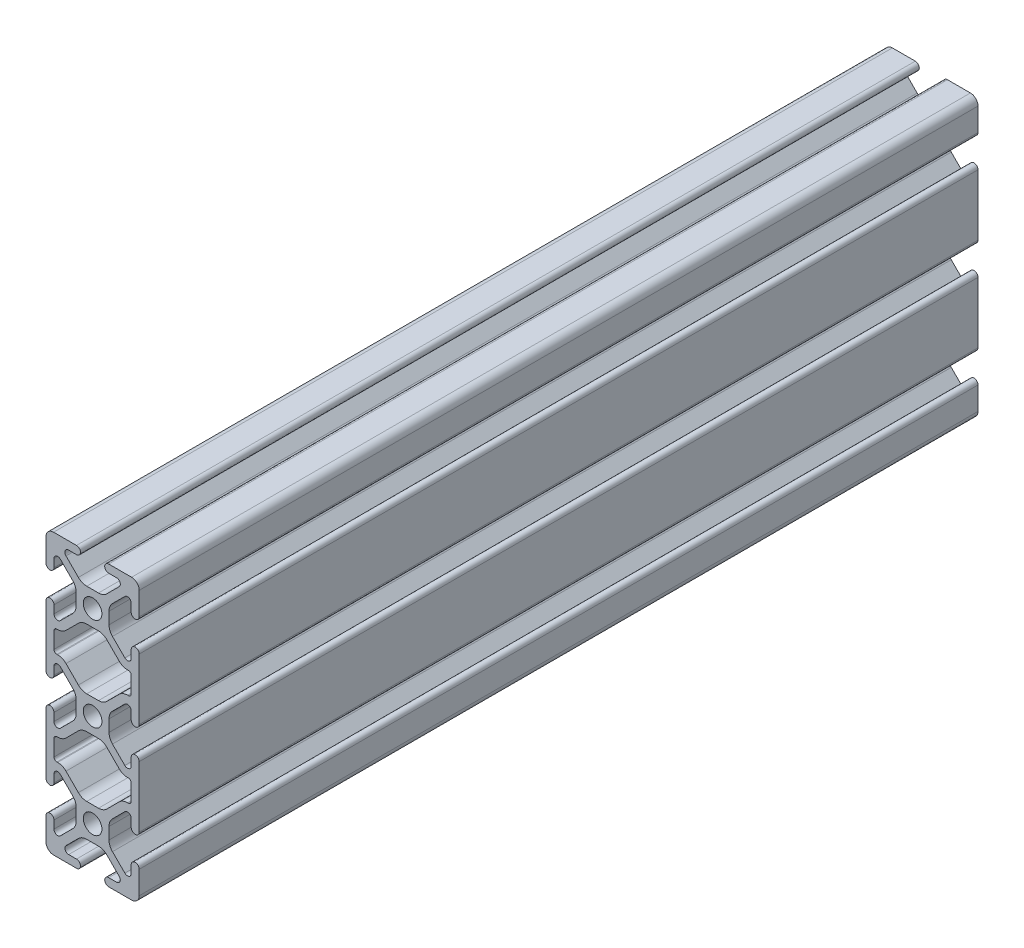
from build123d import *

# Parameters (mm, degrees)
SKETCH1_R           = 2.5
BOSS_EXTRUDE1_DEPTH = 225


with BuildPart() as part:
    # Sketch1 → Boss-Extrude1 (new body)
    with BuildSketch(Plane(origin=(0, 0, -225), x_dir=(-1, 0, 0), z_dir=(0, 0, -1))):
        with BuildLine():
            Line((10.36, -29.32), (10.36, -31.428177128))
            ThreePointArc((10.36, -31.428177128), (9.741558145, -32.353740773), (8.649781386, -32.136572873))
            Line((8.649781386, -32.136572873), (5.328471504, -28.815262992))
            ThreePointArc((5.328471504, -28.815262992), (4.641301883, -27.786840976), (4.400000001, -26.573734496))
            Line((4.400000001, -26.573734496), (4.400000001, -23.426265505))
            ThreePointArc((4.400000001, -23.426265505), (4.641301883, -22.213159025), (5.328471504, -21.184737009))
            Line((5.328471504, -21.184737009), (8.649781387, -17.863427126))
            ThreePointArc((8.649781387, -17.863427126), (9.741558146, -17.646259226), (10.36, -18.57182287))
            Line((10.36, -18.57182287), (10.36, -20.68))
            ThreePointArc((10.36, -20.68), (11.43, -21.75), (12.5, -20.68))
            Line((12.5, -20.68), (12.5, -4.32))
            ThreePointArc((12.5, -4.32), (11.43, -3.25), (10.36, -4.32))
            Line((10.36, -4.32), (10.36, -6.428177131))
            ThreePointArc((10.36, -6.428177131), (9.741558146, -7.353740774), (8.649781388, -7.136572875))
            Line((8.649781388, -7.136572875), (5.328471504, -3.815262991))
            ThreePointArc((5.328471504, -3.815262991), (4.641301883, -2.786840975), (4.400000001, -1.573734495))
            Line((4.400000001, -1.573734495), (4.400000001, 1.573734496))
            ThreePointArc((4.400000001, 1.573734496), (4.641301883, 2.786840976), (5.328471504, 3.815262992))
            Line((5.328471504, 3.815262992), (8.649781387, 7.136572874))
            ThreePointArc((8.649781387, 7.136572874), (9.741558145, 7.353740774), (10.36, 6.42817713))
            Line((10.36, 6.42817713), (10.36, 4.32))
            ThreePointArc((10.36, 4.32), (11.43, 3.25), (12.5, 4.32))
            Line((12.5, 4.32), (12.5, 20.68))
            ThreePointArc((12.5, 20.68), (11.43, 21.75), (10.36, 20.68))
            Line((10.36, 20.68), (10.36, 18.57182287))
            ThreePointArc((10.36, 18.57182287), (9.741558146, 17.646259226), (8.649781387, 17.863427126))
            Line((8.649781387, 17.863427126), (5.328471504, 21.184737009))
            ThreePointArc((5.328471504, 21.184737009), (4.641301883, 22.213159025), (4.400000001, 23.426265505))
            Line((4.400000001, 23.426265505), (4.400000001, 26.573734496))
            ThreePointArc((4.400000001, 26.573734496), (4.641301883, 27.786840976), (5.328471504, 28.815262992))
            Line((5.328471504, 28.815262992), (8.649781386, 32.136572873))
            ThreePointArc((8.649781386, 32.136572873), (9.741558145, 32.353740773), (10.36, 31.428177128))
            Line((10.36, 31.428177128), (10.36, 29.32))
            ThreePointArc((10.36, 29.32), (11.43, 28.25), (12.5, 29.32))
            Line((12.5, 29.32), (12.5, 35.46896145))
            ThreePointArc((12.5, 35.46896145), (11.905122582, 36.905122582), (10.46896145, 37.5))
            Line((10.46896145, 37.5), (4.320000001, 37.5))
            ThreePointArc((4.320000001, 37.5), (3.250000001, 36.43), (4.320000001, 35.360000001))
            Line((4.320000001, 35.360000001), (6.428177129, 35.360000001))
            ThreePointArc((6.428177129, 35.360000001), (7.353740774, 34.741558145), (7.136572874, 33.649781386))
            Line((7.136572874, 33.649781386), (3.815262992, 30.328471504))
            ThreePointArc((3.815262992, 30.328471504), (2.786840977, 29.641301883), (1.573734496, 29.400000001))
            Line((1.573734496, 29.400000001), (-1.573734495, 29.400000001))
            ThreePointArc((-1.573734495, 29.400000001), (-2.786840975, 29.641301883), (-3.815262991, 30.328471504))
            Line((-3.815262991, 30.328471504), (-7.136572873, 33.649781386))
            ThreePointArc((-7.136572873, 33.649781386), (-7.353740772, 34.741558145), (-6.428177128, 35.360000001))
            Line((-6.428177128, 35.360000001), (-4.319999999, 35.360000001))
            ThreePointArc((-4.319999999, 35.360000001), (-3.25, 36.43), (-4.319999999, 37.5))
            Line((-4.319999999, 37.5), (-10.46896145, 37.5))
            ThreePointArc((-10.46896145, 37.5), (-11.905122582, 36.905122582), (-12.5, 35.46896145))
            Line((-12.5, 35.46896145), (-12.5, 29.32))
            ThreePointArc((-12.5, 29.32), (-11.43, 28.25), (-10.36, 29.32))
            Line((-10.36, 29.32), (-10.36, 31.428177128))
            ThreePointArc((-10.36, 31.428177128), (-9.741558145, 32.353740773), (-8.649781385, 32.136572873))
            Line((-8.649781385, 32.136572873), (-5.328471504, 28.815262992))
            ThreePointArc((-5.328471504, 28.815262992), (-4.641301882, 27.786840976), (-4.4, 26.573734496))
            Line((-4.4, 26.573734496), (-4.4, 23.426265505))
            ThreePointArc((-4.4, 23.426265505), (-4.641301882, 22.213159024), (-5.328471504, 21.184737008))
            Line((-5.328471504, 21.184737008), (-8.649781386, 17.863427126))
            ThreePointArc((-8.649781386, 17.863427126), (-9.741558145, 17.646259226), (-10.36, 18.57182287))
            Line((-10.36, 18.57182287), (-10.36, 20.68))
            ThreePointArc((-10.36, 20.68), (-11.43, 21.75), (-12.5, 20.68))
            Line((-12.5, 20.68), (-12.5, 4.32))
            ThreePointArc((-12.5, 4.32), (-11.43, 3.25), (-10.36, 4.32))
            Line((-10.36, 4.32), (-10.36, 6.42817713))
            ThreePointArc((-10.36, 6.42817713), (-9.741558145, 7.353740774), (-8.649781386, 7.136572874))
            Line((-8.649781386, 7.136572874), (-5.328471504, 3.815262992))
            ThreePointArc((-5.328471504, 3.815262992), (-4.641301882, 2.786840976), (-4.4, 1.573734495))
            Line((-4.4, 1.573734495), (-4.4, -1.573734494))
            ThreePointArc((-4.4, -1.573734494), (-4.641301882, -2.786840975), (-5.328471504, -3.815262991))
            Line((-5.328471504, -3.815262991), (-8.649781387, -7.136572875))
            ThreePointArc((-8.649781387, -7.136572875), (-9.741558145, -7.353740774), (-10.36, -6.428177131))
            Line((-10.36, -6.428177131), (-10.36, -4.32))
            ThreePointArc((-10.36, -4.32), (-11.43, -3.25), (-12.5, -4.32))
            Line((-12.5, -4.32), (-12.5, -20.68))
            ThreePointArc((-12.5, -20.68), (-11.43, -21.75), (-10.36, -20.68))
            Line((-10.36, -20.68), (-10.36, -18.57182287))
            ThreePointArc((-10.36, -18.57182287), (-9.741558145, -17.646259226), (-8.649781386, -17.863427126))
            Line((-8.649781386, -17.863427126), (-5.328471504, -21.184737008))
            ThreePointArc((-5.328471504, -21.184737008), (-4.641301882, -22.213159024), (-4.4, -23.426265505))
            Line((-4.4, -23.426265505), (-4.4, -26.573734496))
            ThreePointArc((-4.4, -26.573734496), (-4.641301882, -27.786840976), (-5.328471504, -28.815262992))
            Line((-5.328471504, -28.815262992), (-8.649781385, -32.136572873))
            ThreePointArc((-8.649781385, -32.136572873), (-9.741558145, -32.353740773), (-10.36, -31.428177128))
            Line((-10.36, -31.428177128), (-10.36, -29.32))
            ThreePointArc((-10.36, -29.32), (-11.43, -28.25), (-12.5, -29.32))
            Line((-12.5, -29.32), (-12.5, -35.46896145))
            ThreePointArc((-12.5, -35.46896145), (-11.905122582, -36.905122582), (-10.46896145, -37.5))
            Line((-10.46896145, -37.5), (-4.319999999, -37.5))
            ThreePointArc((-4.319999999, -37.5), (-3.25, -36.43), (-4.319999999, -35.360000001))
            Line((-4.319999999, -35.360000001), (-6.428177128, -35.360000001))
            ThreePointArc((-6.428177128, -35.360000001), (-7.353740772, -34.741558145), (-7.136572873, -33.649781386))
            Line((-7.136572873, -33.649781386), (-3.815262991, -30.328471504))
            ThreePointArc((-3.815262991, -30.328471504), (-2.786840975, -29.641301883), (-1.573734495, -29.400000001))
            Line((-1.573734495, -29.400000001), (1.573734496, -29.400000001))
            ThreePointArc((1.573734496, -29.400000001), (2.786840977, -29.641301883), (3.815262992, -30.328471504))
            Line((3.815262992, -30.328471504), (7.136572874, -33.649781386))
            ThreePointArc((7.136572874, -33.649781386), (7.353740774, -34.741558145), (6.428177129, -35.360000001))
            Line((6.428177129, -35.360000001), (4.320000001, -35.360000001))
            ThreePointArc((4.320000001, -35.360000001), (3.250000001, -36.43), (4.320000001, -37.5))
            Line((4.320000001, -37.5), (10.46896145, -37.5))
            ThreePointArc((10.46896145, -37.5), (11.905122582, -36.905122582), (12.5, -35.46896145))
            Line((12.5, -35.46896145), (12.5, -29.32))
            ThreePointArc((12.5, -29.32), (11.43, -28.25), (10.36, -29.32))
        make_face()
        with Locations((0, -25)):
            Circle(SKETCH1_R, mode=Mode.SUBTRACT)
        with Locations((0, 25)):
            Circle(SKETCH1_R, mode=Mode.SUBTRACT)
        Circle(SKETCH1_R, mode=Mode.SUBTRACT)
        with BuildLine():
            Line((10.36, -10.330000001), (10.36, -14.67))
            ThreePointArc((10.36, -14.67), (10.137401154, -15.207401154), (9.6, -15.43))
            Line((9.6, -15.43), (9.358177132, -15.43))
            ThreePointArc((9.358177132, -15.43), (8.155853572, -15.669157026), (7.136572875, -16.350218613))
            Line((7.136572875, -16.350218613), (3.815262992, -19.671528496))
            ThreePointArc((3.815262992, -19.671528496), (2.786840976, -20.358698118), (1.573734496, -20.6))
            Line((1.573734496, -20.6), (-1.573734495, -20.6))
            ThreePointArc((-1.573734495, -20.6), (-2.786840975, -20.358698118), (-3.815262991, -19.671528496))
            Line((-3.815262991, -19.671528496), (-7.136572874, -16.350218613))
            ThreePointArc((-7.136572874, -16.350218613), (-8.155853571, -15.669157026), (-9.358177131, -15.43))
            Line((-9.358177131, -15.43), (-9.6, -15.43))
            ThreePointArc((-9.6, -15.43), (-10.137401154, -15.207401154), (-10.36, -14.67))
            Line((-10.36, -14.67), (-10.36, -10.330000001))
            ThreePointArc((-10.36, -10.330000001), (-10.137401154, -9.792598847), (-9.6, -9.570000001))
            Line((-9.6, -9.570000001), (-9.358177131, -9.570000001))
            ThreePointArc((-9.358177131, -9.570000001), (-8.155853572, -9.330842975), (-7.136572875, -8.649781387))
            Line((-7.136572875, -8.649781387), (-3.815262992, -5.328471504))
            ThreePointArc((-3.815262992, -5.328471504), (-2.786840976, -4.641301883), (-1.573734495, -4.400000001))
            Line((-1.573734495, -4.400000001), (1.573734496, -4.400000001))
            ThreePointArc((1.573734496, -4.400000001), (2.786840976, -4.641301883), (3.815262992, -5.328471504))
            Line((3.815262992, -5.328471504), (7.136572875, -8.649781387))
            ThreePointArc((7.136572875, -8.649781387), (8.155853572, -9.330842975), (9.358177132, -9.570000001))
            Line((9.358177132, -9.570000001), (9.6, -9.570000001))
            ThreePointArc((9.6, -9.570000001), (10.137401154, -9.792598847), (10.36, -10.330000001))
        make_face(mode=Mode.SUBTRACT)
        with BuildLine():
            Line((10.36, 14.67), (10.36, 10.330000001))
            ThreePointArc((10.36, 10.330000001), (10.137401154, 9.792598847), (9.6, 9.570000001))
            Line((9.6, 9.570000001), (9.358177131, 9.570000001))
            ThreePointArc((9.358177131, 9.570000001), (8.155853571, 9.330842975), (7.136572874, 8.649781387))
            Line((7.136572874, 8.649781387), (3.815262991, 5.328471504))
            ThreePointArc((3.815262991, 5.328471504), (2.786840975, 4.641301882), (1.573734495, 4.4))
            Line((1.573734495, 4.4), (-1.573734494, 4.4))
            ThreePointArc((-1.573734494, 4.4), (-2.786840975, 4.641301882), (-3.815262991, 5.328471504))
            Line((-3.815262991, 5.328471504), (-7.136572874, 8.649781387))
            ThreePointArc((-7.136572874, 8.649781387), (-8.155853571, 9.330842975), (-9.358177131, 9.570000001))
            Line((-9.358177131, 9.570000001), (-9.6, 9.570000001))
            ThreePointArc((-9.6, 9.570000001), (-10.137401154, 9.792598847), (-10.36, 10.330000001))
            Line((-10.36, 10.330000001), (-10.36, 14.67))
            ThreePointArc((-10.36, 14.67), (-10.137401154, 15.207401154), (-9.6, 15.43))
            Line((-9.6, 15.43), (-9.358177131, 15.43))
            ThreePointArc((-9.358177131, 15.43), (-8.155853571, 15.669157026), (-7.136572874, 16.350218613))
            Line((-7.136572874, 16.350218613), (-3.815262991, 19.671528496))
            ThreePointArc((-3.815262991, 19.671528496), (-2.786840975, 20.358698118), (-1.573734495, 20.6))
            Line((-1.573734495, 20.6), (1.573734496, 20.6))
            ThreePointArc((1.573734496, 20.6), (2.786840976, 20.358698118), (3.815262992, 19.671528496))
            Line((3.815262992, 19.671528496), (7.136572875, 16.350218613))
            ThreePointArc((7.136572875, 16.350218613), (8.155853572, 15.669157026), (9.358177132, 15.43))
            Line((9.358177132, 15.43), (9.6, 15.43))
            ThreePointArc((9.6, 15.43), (10.137401154, 15.207401154), (10.36, 14.67))
        make_face(mode=Mode.SUBTRACT)
    extrude(amount=-BOSS_EXTRUDE1_DEPTH)


solid = part.part
